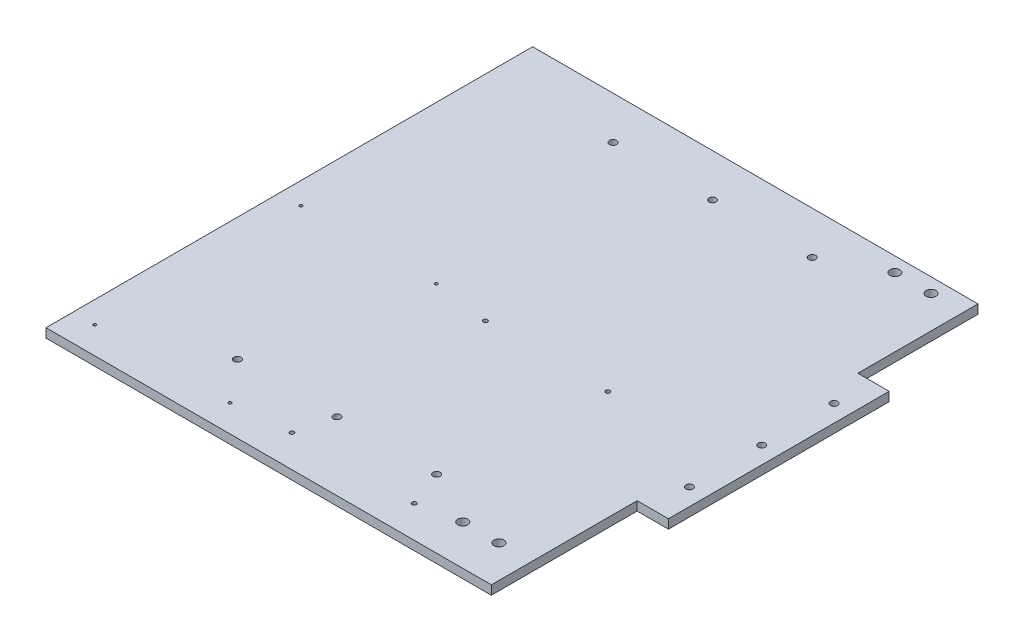
from build123d import *

# Parameters (mm, degrees)
SKETCH1_W           = 313
SKETCH1_H           = 342
BOSS_EXTRUDE1_DEPTH = 6.35
SKETCH3_W           = 22
SKETCH3_H           = 155.14040353
SKETCH3_R           = 2.5
BOSS_EXTRUDE2_DEPTH = 6.35
SKETCH2_R           = 2.5
CUT_EXTRUDE1_DEPTH  = 7.35
SKETCH4_R           = 3.5
CUT_EXTRUDE2_DEPTH  = 7.35
SKETCH5_R           = 1.5
SKETCH5_R_2         = 1.05
CUT_EXTRUDE3_DEPTH  = 7.35


with BuildPart() as part:
    # Sketch1 → Boss-Extrude1 (new body)
    with BuildSketch(Plane(origin=(0, 0, 0), x_dir=(1, 0, 0), z_dir=(0, 1, 0))):
        Rectangle(SKETCH1_W, SKETCH1_H)
    extrude(amount=-BOSS_EXTRUDE1_DEPTH)

    # Sketch3 → Boss-Extrude2 (add)
    with BuildSketch(Plane(origin=(0, 0, 0), x_dir=(1, 0, 0), z_dir=(0, 1, 0))):
        with Locations((167.5, 9)):
            Rectangle(SKETCH3_W, SKETCH3_H)
        with Locations((166.5, 9)):
            Circle(SKETCH3_R, mode=Mode.SUBTRACT)
        with Locations((166.5, -41.8)):
            Circle(SKETCH3_R, mode=Mode.SUBTRACT)
        with Locations((166.5, 59.8)):
            Circle(SKETCH3_R, mode=Mode.SUBTRACT)
    extrude(amount=-BOSS_EXTRUDE2_DEPTH)

    # Sketch2 → Cut-Extrude1 (cut, through all)
    with BuildSketch(Plane(origin=(0, 0, 0), x_dir=(1, 0, 0), z_dir=(0, 1, 0))):
        with Locations((0, -123)):
            Circle(SKETCH2_R)
        with Locations((-70, -123)):
            Circle(SKETCH2_R)
        with Locations((70, -123)):
            Circle(SKETCH2_R)
        with Locations((-70, 141)):
            Circle(SKETCH2_R)
        with Locations((0, 141)):
            Circle(SKETCH2_R)
        with Locations((70, 141)):
            Circle(SKETCH2_R)
    extrude(amount=-CUT_EXTRUDE1_DEPTH, mode=Mode.SUBTRACT)

    # Sketch4 → Cut-Extrude2 (cut, through all)
    with BuildSketch(Plane(origin=(0, 0, 0), x_dir=(1, 0, 0), z_dir=(0, 1, 0))):
        with Locations((133.64, -142.84)):
            Circle(SKETCH4_R)
        with Locations((108.24, -142.84)):
            Circle(SKETCH4_R)
    cut_extrude2 = extrude(amount=-CUT_EXTRUDE2_DEPTH, mode=Mode.SUBTRACT)

    # Mirror1: Cut-Extrude2 across plane
    add(cut_extrude2.mirror(Plane(origin=(0, 0, -9), x_dir=(1, 0, 0), z_dir=(0, 0, -1))), mode=Mode.SUBTRACT)

    # Sketch5 → Cut-Extrude3 (cut, through all)
    with BuildSketch(Plane(origin=(0, 0, 0), x_dir=(1, 0, 0), z_dir=(0, 1, 0))):
        with Locations((79.770037453, -148.470411985)):
            Circle(SKETCH5_R)
        with Locations((-6.229962547, -148.470411985)):
            Circle(SKETCH5_R)
        with Locations((-6.229962547, -12.470411985)):
            Circle(SKETCH5_R)
        with Locations((79.770037453, -12.470411985)):
            Circle(SKETCH5_R)
        with Locations((-46.113857678, -7.113857678)):
            Circle(SKETCH5_R_2)
        with Locations((-46.113857678, -152.113857678)):
            Circle(SKETCH5_R_2)
        with Locations((-141.113857678, -7.113857678)):
            Circle(SKETCH5_R_2)
        with Locations((-141.113857678, -152.113857678)):
            Circle(SKETCH5_R_2)
    extrude(amount=-CUT_EXTRUDE3_DEPTH, mode=Mode.SUBTRACT)


solid = part.part
